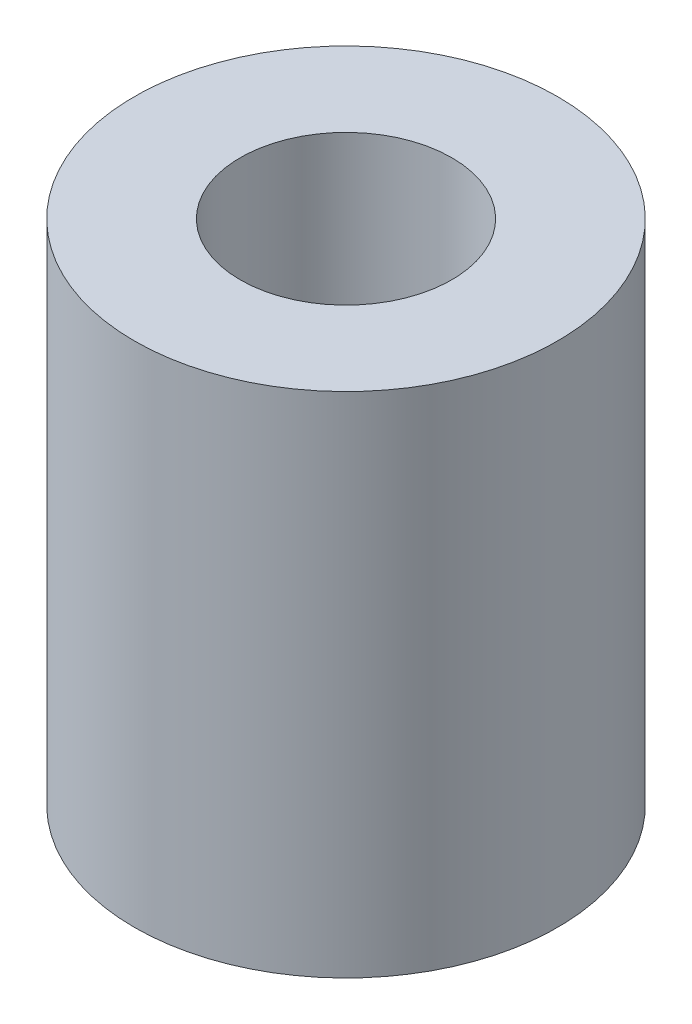
from build123d import *

# Parameters (mm, degrees)
SKETCH1_R           = 2
SKETCH1_R_2         = 1
BOSS_EXTRUDE1_DEPTH = 4.8


with BuildPart() as part:
    # Sketch1 → Boss-Extrude1 (new body)
    with BuildSketch(Plane(origin=(0, 0, 0), x_dir=(1, 0, 0), z_dir=(0, 1, 0))):
        Circle(SKETCH1_R)
        Circle(SKETCH1_R_2, mode=Mode.SUBTRACT)
    extrude(amount=BOSS_EXTRUDE1_DEPTH)


solid = part.part
